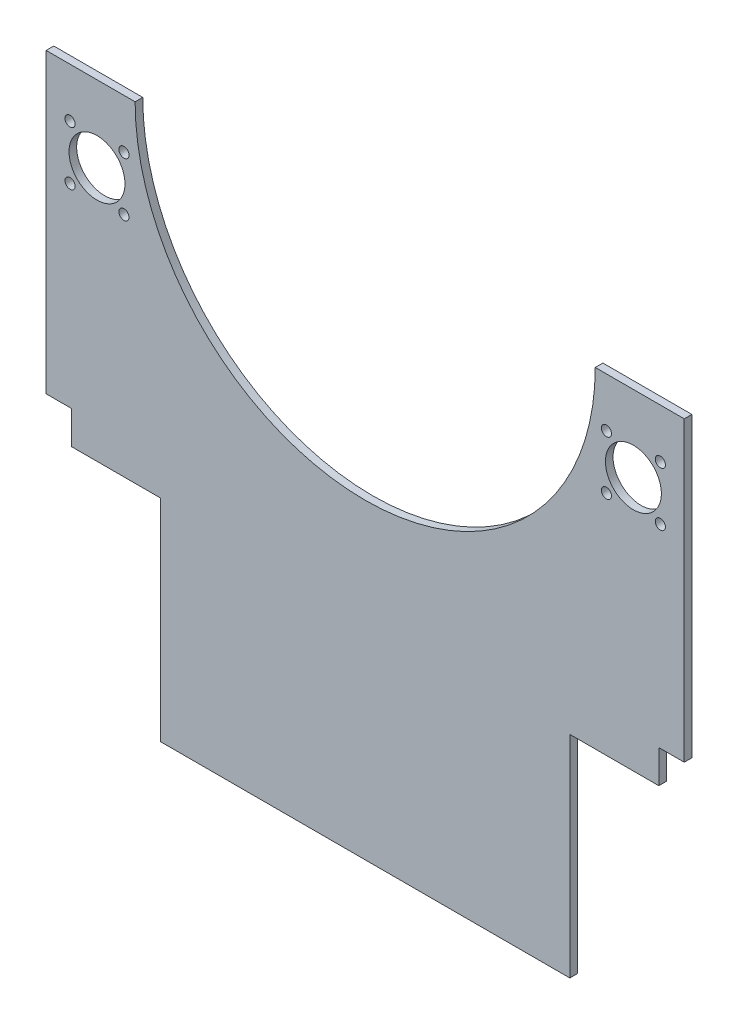
from build123d import *

# Parameters (mm, degrees)
ESQUISSE1_R      = 11
ESQUISSE1_R_2    = 2
EXTRUSION1_DEPTH = 3


with BuildPart() as part:
    # Esquisse1 → Extrusion1 (new body)
    with BuildSketch(Plane.XY):
        with BuildLine():
            Line((125.5, 0), (125.5, -117))
            Line((125.5, -117), (115.5, -117))
            Line((115.5, -117), (115.5, -130))
            Line((115.5, -130), (80.5, -130))
            Line((80.5, -130), (80.5, -213))
            Line((80.5, -213), (-80.5, -213))
            Line((-80.5, -213), (-80.5, -130))
            Line((-80.5, -130), (-115.5, -130))
            Line((-115.5, -130), (-115.5, -117))
            Line((-115.5, -117), (-125.5, -117))
            Line((-125.5, -117), (-125.5, 0))
            Line((-125.5, 0), (-90.5, 0))
            ThreePointArc((-90.5, 0), (0, -90.5), (90.5, 0))
            Line((90.5, 0), (125.5, 0))
        make_face()
        with Locations((-105.5, -30)):
            Circle(ESQUISSE1_R, mode=Mode.SUBTRACT)
        with Locations((116.106601718, -19.393398282)):
            Circle(ESQUISSE1_R_2, mode=Mode.SUBTRACT)
        with Locations((94.893398282, -40.606601718)):
            Circle(ESQUISSE1_R_2, mode=Mode.SUBTRACT)
        with Locations((-94.893398282, -19.393398282)):
            Circle(ESQUISSE1_R_2, mode=Mode.SUBTRACT)
        with Locations((-116.106601718, -40.606601718)):
            Circle(ESQUISSE1_R_2, mode=Mode.SUBTRACT)
        with Locations((-94.893398282, -40.606601718)):
            Circle(ESQUISSE1_R_2, mode=Mode.SUBTRACT)
        with Locations((116.106601718, -40.606601718)):
            Circle(ESQUISSE1_R_2, mode=Mode.SUBTRACT)
        with Locations((94.893398282, -19.393398282)):
            Circle(ESQUISSE1_R_2, mode=Mode.SUBTRACT)
        with Locations((105.5, -30)):
            Circle(ESQUISSE1_R, mode=Mode.SUBTRACT)
        with Locations((-116.106601718, -19.393398282)):
            Circle(ESQUISSE1_R_2, mode=Mode.SUBTRACT)
    extrude(amount=EXTRUSION1_DEPTH)


solid = part.part
